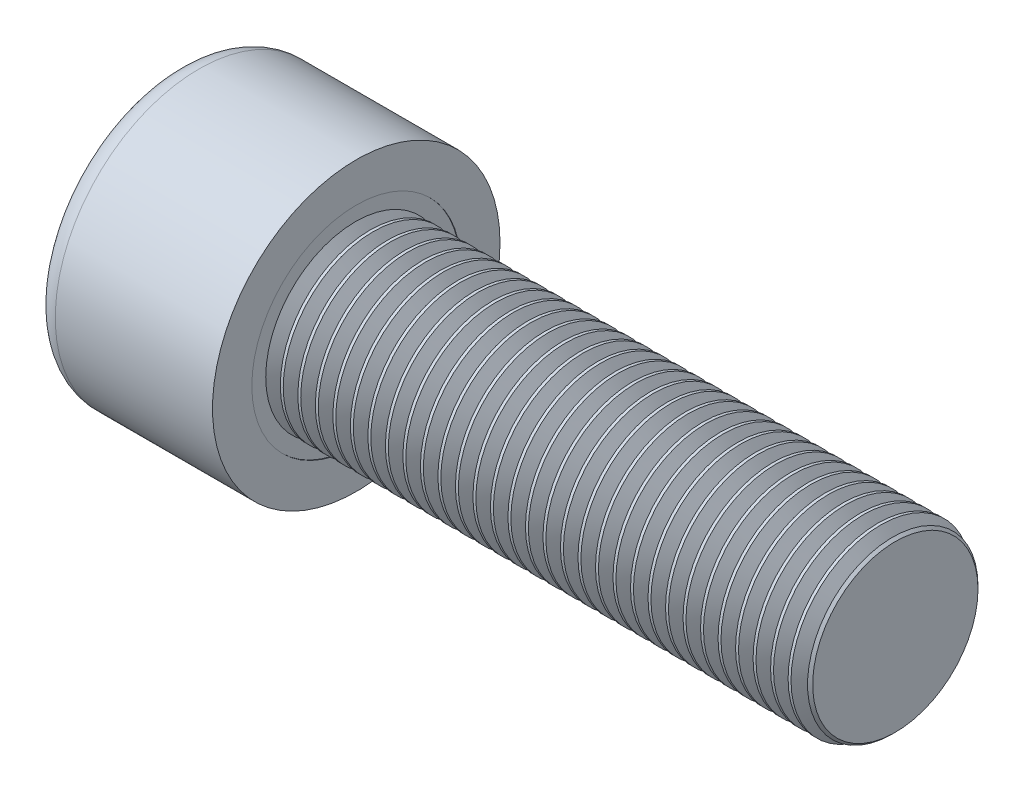
from build123d import *

# Parameters (mm, degrees)
SKETCH1_R           = 8
BASEHEAD_DEPTH      = 10
SKETCH2_R           = 5
BASEBODY_DEPTH      = 30
HEXAGONSOCKET_DEPTH = 5
TOPFILLET_R         = 1.25
CHAMFER1_SIZE       = 0.4
LPATTERN10_COUNT    = 31
LPATTERN10_PITCH    = 0.9744


with BuildPart() as part:
    # Sketch1 → BaseHead (new body)
    with BuildSketch(Plane(origin=(0, 0, 0), x_dir=(0, 0, -1), z_dir=(1, 0, 0))):
        Circle(SKETCH1_R)
    extrude(amount=BASEHEAD_DEPTH)

    # Sketch2 → BaseBody (add)
    with BuildSketch(Plane(origin=(10, 0, 0), x_dir=(0, 0, -1), z_dir=(1, 0, 0))):
        Circle(SKETCH2_R)
    extrude(amount=BASEBODY_DEPTH)

    # Sketch3 → HexagonSocket (cut)
    with BuildSketch(Plane(origin=(0, 0, 0), x_dir=(0, 0, -1), z_dir=(1, 0, 0))):
        Polygon((4.618802154, 0), (2.309401077, 4), (-2.309401077, 4), (-4.618802154, 0), (-2.309401077, -4), (2.309401077, -4), align=None)
    extrude(amount=HEXAGONSOCKET_DEPTH, mode=Mode.SUBTRACT)

    # Sketch4 → Cut-Revolve1 (revolve, cut)
    with BuildSketch(Plane(origin=(-4.19613823, 0.75, 0), x_dir=(-1, 0, 0), z_dir=(0, 0, 1))):
        Polygon((-9.19613823, 4.75), (-11.505539306, 0.75), (-9.19613823, 0.75), align=None)
    revolve(axis=Axis((0.838992387, 0, 0), (-1, 0, 0)), mode=Mode.SUBTRACT)

    # TopFillet
    topfillet_edges = [part.edges().sort_by_distance(p)[0] for p in [
        (0, 0, 8),
    ]]
    fillet(topfillet_edges, radius=TOPFILLET_R)

    # Chamfer1
    chamfer1_edges = [part.edges().sort_by_distance(p)[0] for p in [
        (40, 0, 5),
    ]]
    chamfer(chamfer1_edges, length=CHAMFER1_SIZE)

    # Sketch5 → Cut-Revolve10 (revolve, cut)
    with BuildSketch(Plane.XY):
        Polygon((39.6, 4.296787372), (40.006, 5), (40.006, 5.812), (39.194, 5.812), (39.194, 5), align=None)
    cut_revolve10 = revolve(axis=Axis((0, 0, 0), (1, 0, 0)), mode=Mode.SUBTRACT)

    # LPattern10: Cut-Revolve10 ×31
    with Locations(*[(-i * LPATTERN10_PITCH, 0, 0) for i in range(1, LPATTERN10_COUNT)]):
        add(cut_revolve10, mode=Mode.SUBTRACT)


solid = part.part
